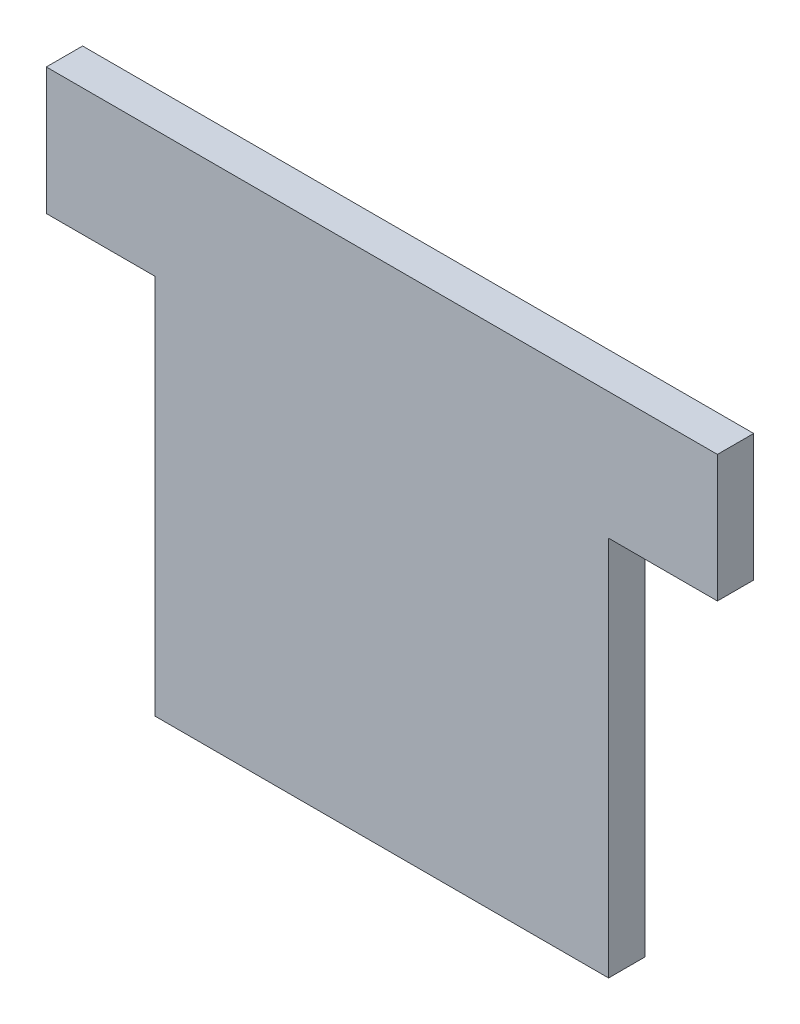
from build123d import *

# Parameters (mm, degrees)
AUFSATZ_LINEAR_AUSTRAGEN1_DEPTH = 2


with BuildPart() as part:
    # Skizze1 → Aufsatz-Linear austragen1 (new body)
    with BuildSketch(Plane.XY):
        Polygon((0, 0), (0, -21), (25, -21), (25, 0), (31, 0), (31, 7), (-6, 7), (-6, 0), align=None)
    extrude(amount=AUFSATZ_LINEAR_AUSTRAGEN1_DEPTH)


solid = part.part
